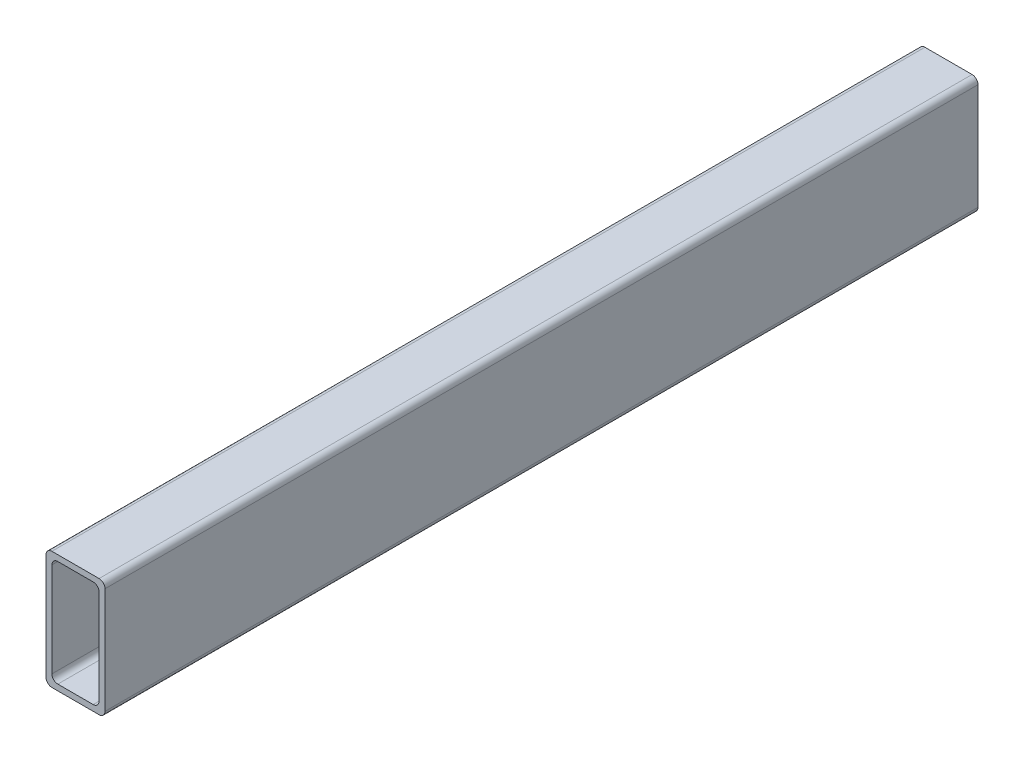
from build123d import *

# Parameters (mm, degrees)
EXTRUDE_1_DEPTH = 370


with BuildPart() as part:
    # Эскиз1 → Бобышка-Вытянуть1 (new body)
    with BuildSketch(Plane.XY):
        with BuildLine():
            Line((-10, 50), (10, 50))
            ThreePointArc((10, 50), (11.767766953, 49.267766953), (12.5, 47.5))
            Line((12.5, 47.5), (12.5, 2.5))
            ThreePointArc((12.5, 2.5), (11.767766953, 0.732233047), (10, 0))
            Line((10, 0), (-10, 0))
            ThreePointArc((-10, 0), (-11.767766953, 0.732233047), (-12.5, 2.5))
            Line((-12.5, 2.5), (-12.5, 47.5))
            ThreePointArc((-12.5, 47.5), (-11.767766953, 49.267766953), (-10, 50))
        make_face()
        with BuildLine():
            Line((-7.5, 47.5), (7.5, 47.5))
            ThreePointArc((7.5, 47.5), (9.267766953, 46.767766953), (10, 45))
            Line((10, 45), (10, 5))
            ThreePointArc((10, 5), (9.267766953, 3.232233047), (7.5, 2.5))
            Line((7.5, 2.5), (-7.5, 2.5))
            ThreePointArc((-7.5, 2.5), (-9.267766953, 3.232233047), (-10, 5))
            Line((-10, 5), (-10, 45))
            ThreePointArc((-10, 45), (-9.267766953, 46.767766953), (-7.5, 47.5))
        make_face(mode=Mode.SUBTRACT)
    extrude(amount=-EXTRUDE_1_DEPTH)


solid = part.part
